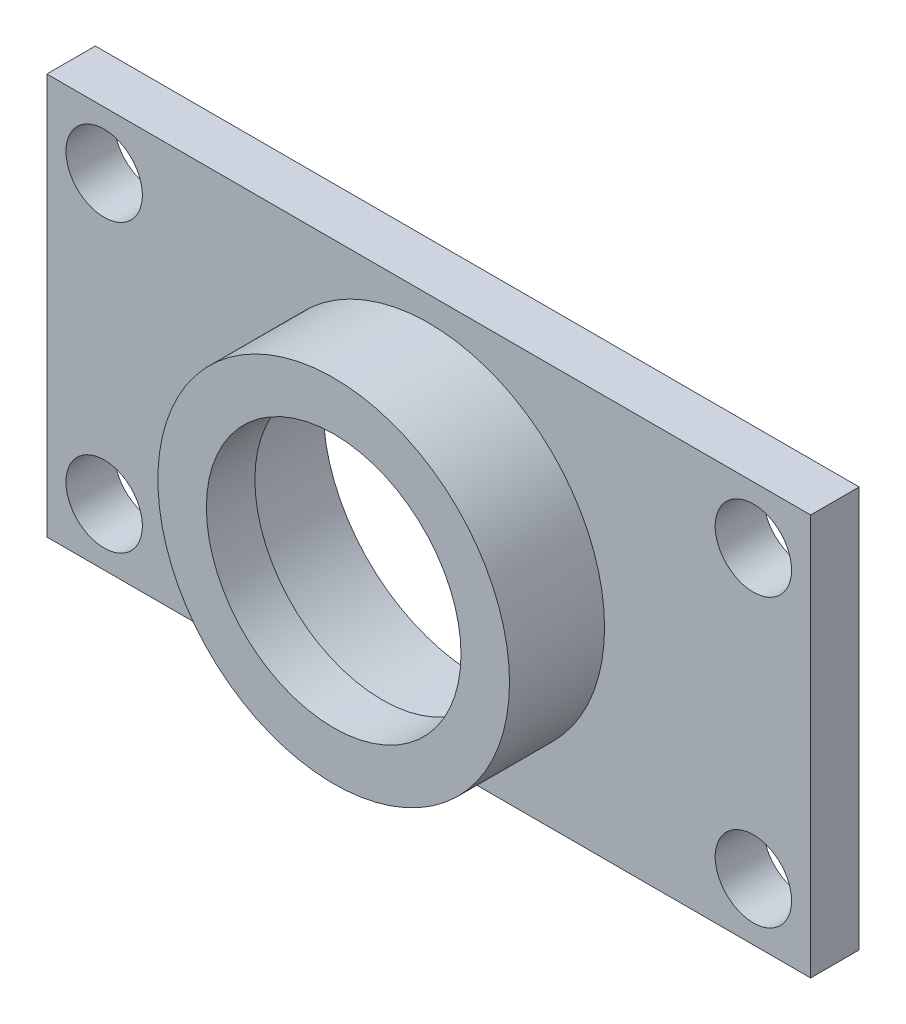
from build123d import *

# Parameters (mm, degrees)
SKETCH2_W           = 40
SKETCH2_H           = 21
BOSS_EXTRUDE1_DEPTH = 2.54
SKETCH4_R           = 9.2075
BOSS_EXTRUDE2_DEPTH = 4.9784
CUT_EXTRUDE2_START  = 7.5184
SKETCH7_R           = 6.6675
CUT_EXTRUDE2_DEPTH  = 2.54
SKETCH8_R           = 1.999996
CUT_EXTRUDE3_DEPTH  = 3.54
SKETCH10_R          = 1.999996
CUT_EXTRUDE4_DEPTH  = 3.54
SKETCH13_R          = 8.0645
CUT_EXTRUDE5_DEPTH  = 4.9784


with BuildPart() as part:
    # Sketch2 → Boss-Extrude1 (new body)
    with BuildSketch(Plane.XY):
        with Locations((20, 10.5)):
            Rectangle(SKETCH2_W, SKETCH2_H)
    extrude(amount=BOSS_EXTRUDE1_DEPTH)

    # Sketch4 → Boss-Extrude2 (add)
    with BuildSketch(Plane.XY.offset(2.54)):
        with Locations((20.0000108, 10.49999932)):
            Circle(SKETCH4_R)
    extrude(amount=BOSS_EXTRUDE2_DEPTH)

    # Sketch7 → Cut-Extrude2 (cut)
    with BuildSketch(Plane.XY.offset(CUT_EXTRUDE2_START)):
        with Locations((20.0000108, 10.49999932)):
            Circle(SKETCH7_R)
    extrude(amount=-CUT_EXTRUDE2_DEPTH, mode=Mode.SUBTRACT)

    # Sketch8 → Cut-Extrude3 (cut, through all)
    with BuildSketch(Plane.XY.offset(2.54)):
        with Locations((37.000006, 18.000006)):
            Circle(SKETCH8_R)
        with Locations((3.0000156, 18.000006)):
            Circle(SKETCH8_R)
    extrude(amount=-CUT_EXTRUDE3_DEPTH, mode=Mode.SUBTRACT)

    # Sketch10 → Cut-Extrude4 (cut, through all)
    with BuildSketch(Plane.XY.offset(2.54)):
        with Locations((37.000006, 2.999994)):
            Circle(SKETCH10_R)
        with Locations((3.0000156, 2.999994)):
            Circle(SKETCH10_R)
    extrude(amount=-CUT_EXTRUDE4_DEPTH, mode=Mode.SUBTRACT)

    # Sketch13 → Cut-Extrude5 (cut)
    with BuildSketch(Plane(origin=(0, 0, 0), x_dir=(-1, 0, 0), z_dir=(0, 0, -1))):
        with Locations((-19.9999892, 10.49999932)):
            Circle(SKETCH13_R)
    extrude(amount=-CUT_EXTRUDE5_DEPTH, mode=Mode.SUBTRACT)


solid = part.part
